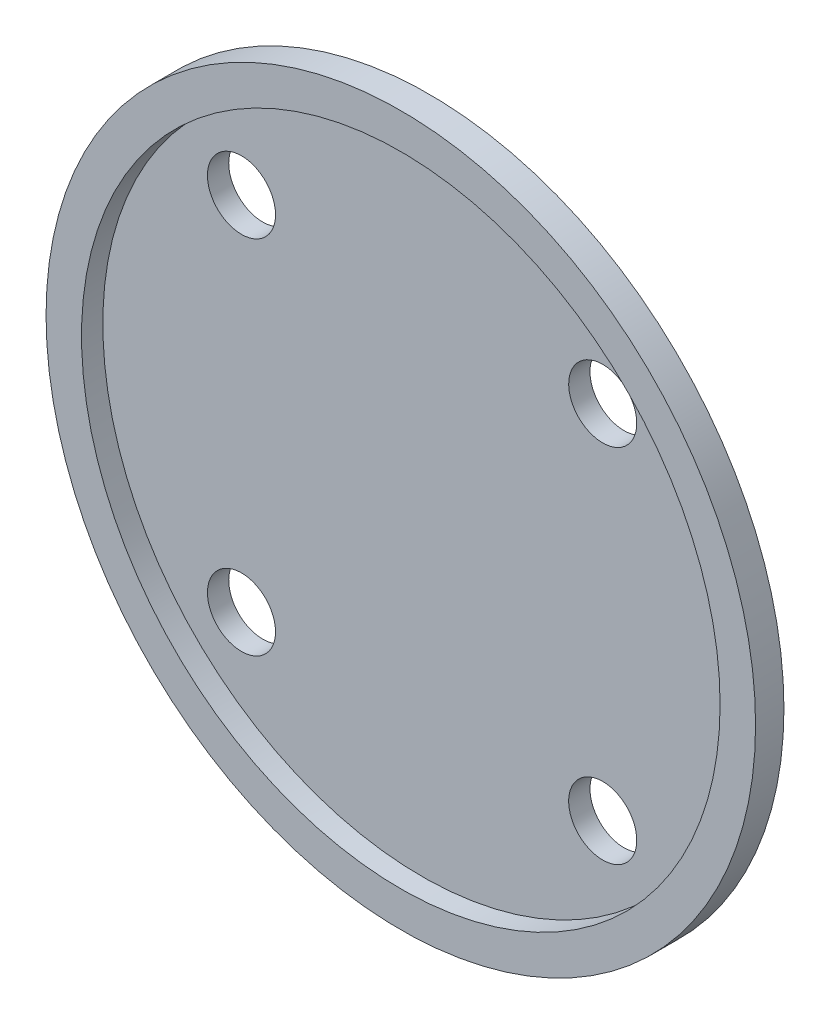
from build123d import *

# Parameters (mm, degrees)
SKETCH1_R           = 25
BOSS_EXTRUDE1_DEPTH = 2
SKETCH1_3_R         = 23.5
BOSS_EXTRUDE2_DEPTH = 1
CUT_EXTRUDE1_REACH  = 4
SKETCH1_4_R         = 22.5
SKETCH1_5_R         = 22.5
BOSS_EXTRUDE3_DEPTH = 0.5
SKETCH2_R           = 2.398519327
CUT_EXTRUDE2_DEPTH  = 10.5
CIRPATTERN1_COUNT   = 4


with BuildPart() as part:
    # Sketch1 → Boss-Extrude1 (new body)
    with BuildSketch(Plane.XY):
        Circle(SKETCH1_R)
    extrude(amount=BOSS_EXTRUDE1_DEPTH)

    # Sketch1_3 → Boss-Extrude2 (add)
    with BuildSketch(Plane.XY):
        Circle(SKETCH1_3_R)
    extrude(amount=-BOSS_EXTRUDE2_DEPTH)

    # Sketch1_4 → Cut-Extrude1 (cut, up to next)
    with BuildSketch(Plane.XY, mode=Mode.PRIVATE) as cut_extrude1_sk1:
        Circle(SKETCH1_4_R)
    cut_extrude1_tool1 = extrude(cut_extrude1_sk1.sketch, amount=CUT_EXTRUDE1_REACH, mode=Mode.PRIVATE) & part.part
    add(cut_extrude1_tool1.solids().sort_by_distance((0, 0, 0))[0], mode=Mode.SUBTRACT)

    # Sketch1_5 → Boss-Extrude3 (add)
    with BuildSketch(Plane.XY):
        Circle(SKETCH1_5_R)
    extrude(amount=BOSS_EXTRUDE3_DEPTH)

    # Sketch2 → Cut-Extrude2 (cut)
    with BuildSketch(Plane(origin=(0, 0, -1), x_dir=(-1, 0, 0), z_dir=(0, 0, -1))):
        with Locations((12.727922061, 12.727922061)):
            Circle(SKETCH2_R)
    cut_extrude2 = extrude(amount=-CUT_EXTRUDE2_DEPTH, mode=Mode.SUBTRACT)

    # CirPattern1: Cut-Extrude2 ×4 about axis
    cirpattern1_axis = Axis((0, 0, 0), (0, 0, 1))
    for i in range(1, CIRPATTERN1_COUNT):
        add(cut_extrude2.rotate(cirpattern1_axis, i * 360 / CIRPATTERN1_COUNT), mode=Mode.SUBTRACT)


solid = part.part
